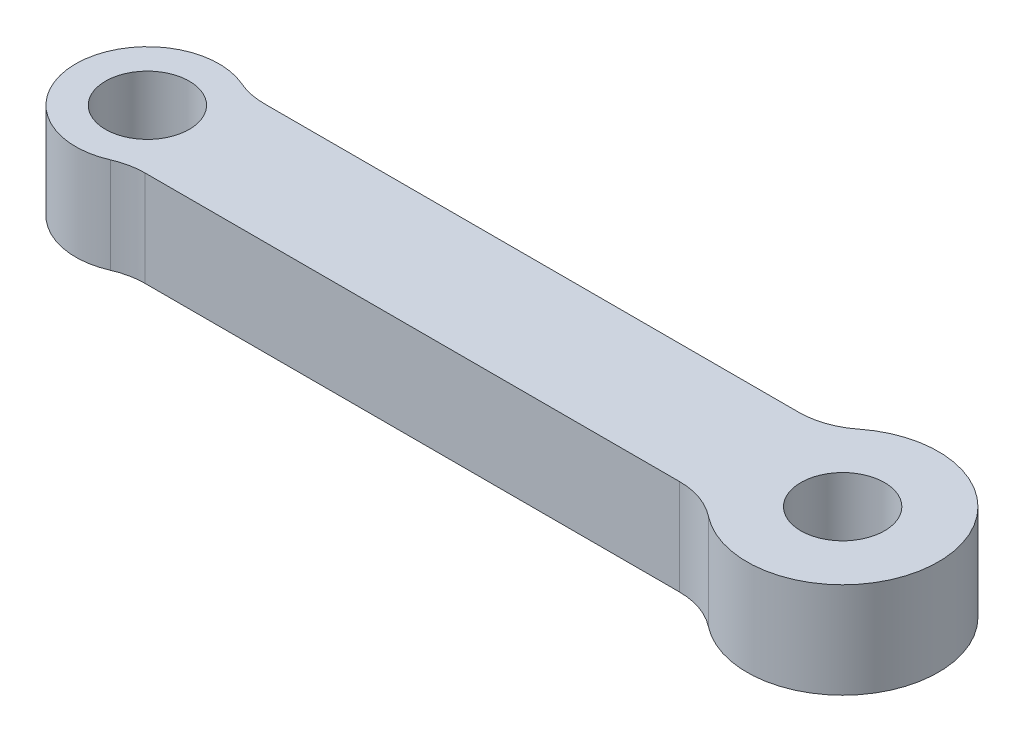
from build123d import *

# Parameters (mm, degrees)
IZIM1_R                     = 1.75
Y_KSEKLIK_EKSTR_ZYON1_DEPTH = 4


with BuildPart() as part:
    # Çizim1 → Yükseklik-Ekstrüzyon1 (new body)
    with BuildSketch(Plane(origin=(0, 0, 0), x_dir=(1, 0, 0), z_dir=(0, 1, 0))):
        with BuildLine():
            Line((-10.218653411, -2.5), (4.071106479, -2.5))
            Line((4.071106479, -2.5), (11.17, -2.5))
            ThreePointArc((11.17, -2.5), (12.151980506, -2.665266452), (13.025768722, -3.142857143))
            ThreePointArc((13.025768722, -3.142857143), (19.500127019, 0), (13.025768722, 3.142857143))
            ThreePointArc((13.025768722, 3.142857143), (12.151980506, 2.665266452), (11.17, 2.5))
            Line((11.17, 2.5), (4.071106479, 2.5))
            Line((4.071106479, 2.5), (-10.218653411, 2.5))
            Line((-10.218653411, 2.5), (-11.17, 2.5))
            ThreePointArc((-11.17, 2.5), (-11.782372436, 2.563164969), (-12.368957881, 2.75))
            ThreePointArc((-12.368957881, 2.75), (-16.567915762, 0), (-12.368957881, -2.75))
            ThreePointArc((-12.368957881, -2.75), (-11.782372436, -2.563164969), (-11.17, -2.5))
            Line((-11.17, -2.5), (-10.218653411, -2.5))
        make_face()
        with Locations((-13.567915762, 0)):
            Circle(IZIM1_R, mode=Mode.SUBTRACT)
        with Locations((15.500127019, 0)):
            Circle(IZIM1_R, mode=Mode.SUBTRACT)
    extrude(amount=Y_KSEKLIK_EKSTR_ZYON1_DEPTH)


solid = part.part
